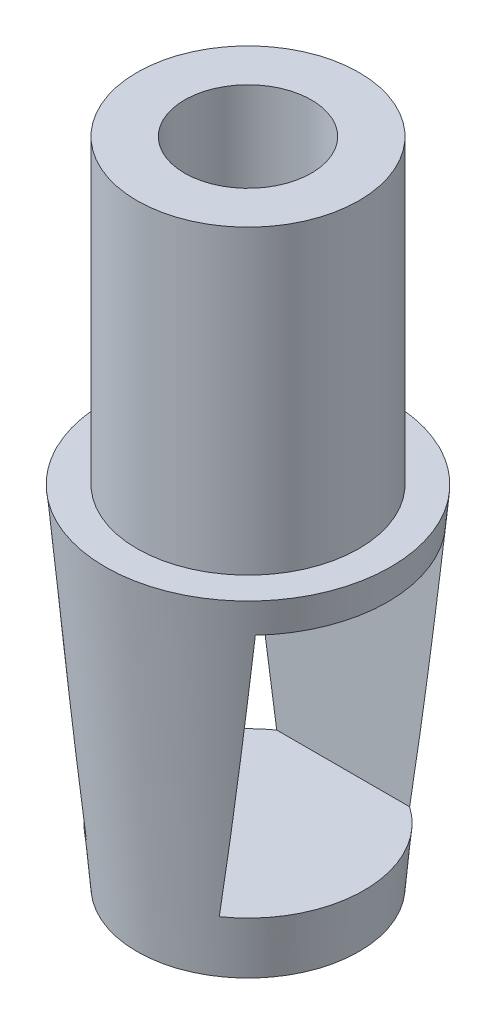
from build123d import *

# Parameters (mm, degrees)
SKETCH1_W               = 3
SKETCH1_H               = 19
SKETCH2_W               = 12
SKETCH2_H               = 16.5
CUT_EXTRUDE1_DEPTH      = 10
CUT_EXTRUDE1_DEPTH_BACK = 10


with BuildPart() as part:
    # Sketch1 → Revolve1 (revolve)
    with BuildSketch(Plane(origin=(0, 0, 0), x_dir=(0, 0, -1), z_dir=(1, 0, 0))):
        with Locations((5.5, 9.5)):
            Rectangle(SKETCH1_W, SKETCH1_H)
        Polygon((7, 0), (4, 0), (0, 0), (0, -22), (7, -22), (9, 0), align=None)
    revolve(axis=Axis((0, 13.924528302, 0), (0, -1, 0)))

    # Sketch2 → Cut-Extrude1 (cut, two sides)
    with BuildSketch(Plane(origin=(0, 0, 0), x_dir=(0, 0, -1), z_dir=(1, 0, 0))) as cut_extrude1_sk:
        with Locations((0, -10.25)):
            Rectangle(SKETCH2_W, SKETCH2_H)
    extrude(amount=CUT_EXTRUDE1_DEPTH, mode=Mode.SUBTRACT)
    extrude(cut_extrude1_sk.sketch, amount=-CUT_EXTRUDE1_DEPTH_BACK, mode=Mode.SUBTRACT)


solid = part.part
